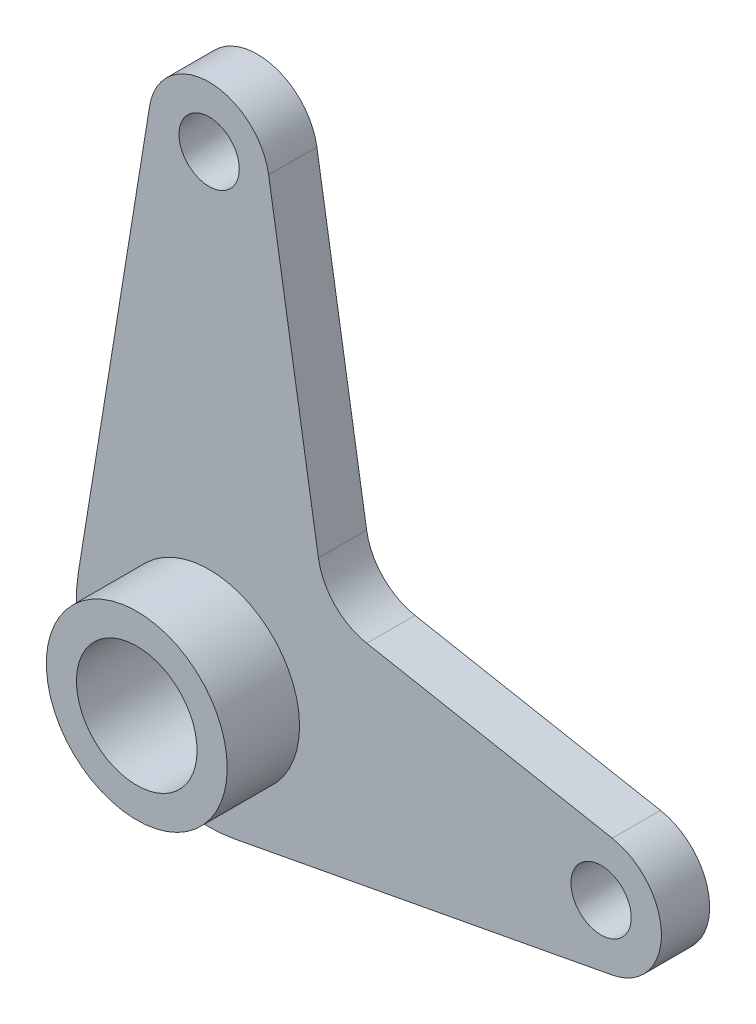
from build123d import *

# Parameters (mm, degrees)
SKETCH1_R           = 5
BOSS_EXTRUDE1_DEPTH = 8
SKETCH2_R           = 15
BOSS_EXTRUDE2_DEPTH = 12
SKETCH3_R           = 10
CUT_EXTRUDE1_DEPTH  = 21


with BuildPart() as part:
    # Sketch1 → Boss-Extrude1 (new body)
    with BuildSketch(Plane.XY):
        with BuildLine():
            Line((-9.871170143, 76.6), (-21.716574315, 3.52))
            ThreePointArc((-21.716574315, 3.52), (-15.360764468, -15.749505229), (4.061538462, -21.62183862))
            Line((4.061538462, -21.62183862), (66.846153846, -9.828108464))
            ThreePointArc((66.846153846, -9.828108464), (75, 0), (66.846153846, 9.828108464))
            Line((66.846153846, 9.828108464), (26.146237666, 17.473354451))
            ThreePointArc((26.146237666, 17.473354451), (20.833525499, 20.319297247), (18.121221369, 25.701462915))
            Line((18.121221369, 25.701462915), (9.871170143, 76.6))
            ThreePointArc((9.871170143, 76.6), (0, 85), (-9.871170143, 76.6))
        make_face()
        with Locations((0, 75)):
            Circle(SKETCH1_R, mode=Mode.SUBTRACT)
        with Locations((65, 0)):
            Circle(SKETCH1_R, mode=Mode.SUBTRACT)
    extrude(amount=BOSS_EXTRUDE1_DEPTH)

    # Sketch2 → Boss-Extrude2 (add)
    with BuildSketch(Plane.XY.offset(8)):
        Circle(SKETCH2_R)
    extrude(amount=BOSS_EXTRUDE2_DEPTH)

    # Sketch3 → Cut-Extrude1 (cut, through all)
    with BuildSketch(Plane.XY.offset(20)):
        Circle(SKETCH3_R)
    extrude(amount=-CUT_EXTRUDE1_DEPTH, mode=Mode.SUBTRACT)


solid = part.part
